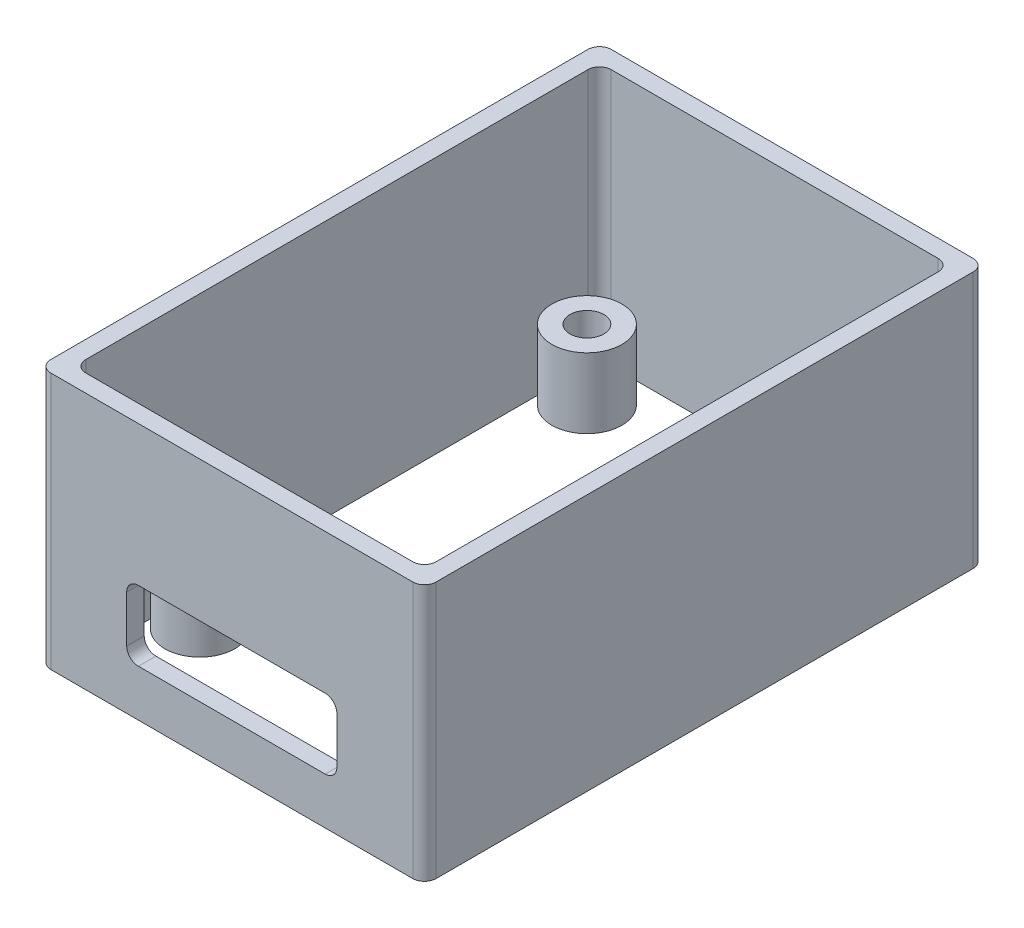
from build123d import *

# Parameters (mm, degrees)
SKETCH1_W                                      = 33
SKETCH1_H                                      = 48
BOSS_EXTRUDE1_DEPTH                            = 22
SKETCH2_W                                      = 30
SKETCH2_H                                      = 45
CUT_EXTRUDE1_DEPTH                             = 25
SKETCH4_R                                      = 3
BOSS_EXTRUDE5_DEPTH                            = 6
BOSS_EXTRUDE5_2_DEPTH                          = 6
BOSS_EXTRUDE5_3_DEPTH                          = 6
BOSS_EXTRUDE5_4_DEPTH                          = 6
SKETCH11_W                                     = 18
SKETCH11_H                                     = 6
CUT_EXTRUDE5_DEPTH                             = 1.5
FILLET5_R                                      = 1
CSK_FOR_M2_5_FLAT_HEAD_MACHINE_SCREW1_AT_COUNT = 2
CSK_FOR_M2_5_FLAT_HEAD_MACHINE_SCREW1_AT_PITCH = 20.32
CSK_FOR_M2_5_FLAT_HEAD_MACHINE_SCREW_2_COUNT   = 2
CSK_FOR_M2_5_FLAT_HEAD_MACHINE_SCREW_2_PITCH   = 38.882192582
CSK_FOR_M2_5_FLAT_HEAD_MACHINE_SCREW_3_COUNT   = 2
CSK_FOR_M2_5_FLAT_HEAD_MACHINE_SCREW_3_PITCH   = 33.15
FILLET6_R                                      = 1


with BuildPart() as part:
    # Sketch1 → Boss-Extrude1 (new body)
    with BuildSketch(Plane(origin=(0, 0, 0), x_dir=(1, 0, 0), z_dir=(0, 1, 0))):
        Rectangle(SKETCH1_W, SKETCH1_H)
    extrude(amount=BOSS_EXTRUDE1_DEPTH)

    # Sketch2 → Cut-Extrude1 (cut)
    with BuildSketch(Plane(origin=(0, 22, 0), x_dir=(1, 0, 0), z_dir=(0, 1, 0))):
        Rectangle(SKETCH2_W, SKETCH2_H)
    extrude(amount=-CUT_EXTRUDE1_DEPTH, mode=Mode.SUBTRACT)

    # Sketch11 → Cut-Extrude5 (cut)
    with BuildSketch(Plane.XY.offset(24)):
        with Locations((0, 7)):
            Rectangle(SKETCH11_W, SKETCH11_H)
    extrude(amount=-CUT_EXTRUDE5_DEPTH, mode=Mode.SUBTRACT)

    # Fillet5
    fillet5_edges = [part.edges().sort_by_distance(p)[0] for p in [
        (15, 11, -22.5),
        (15, 11, 22.5),
        (-15, 11, 22.5),
        (-15, 11, -22.5),
        (-16.5, 11, -24),
        (-16.5, 11, 24),
        (16.5, 11, 24),
        (16.5, 11, -24),
    ]]
    fillet(fillet5_edges, radius=FILLET5_R)

    # Fillet6
    fillet6_edges = [part.edges().sort_by_distance(p)[0] for p in [
        (9, 10, 23.25),
        (9, 4, 23.25),
        (-9, 4, 23.25),
        (-9, 10, 23.25),
    ]]
    fillet(fillet6_edges, radius=FILLET6_R)


with BuildPart() as body_2:
    # Sketch4 → Boss-Extrude5 (new body)
    with BuildSketch(Plane(origin=(0, 2, 0), x_dir=(1, 0, 0), z_dir=(0, 1, 0))):
        with Locations((-10.16, 16.575)):
            Circle(SKETCH4_R)
    extrude(amount=BOSS_EXTRUDE5_DEPTH)


with BuildPart() as body_3:
    # Sketch4 → Boss-Extrude5 2 (new body)
    with BuildSketch(Plane(origin=(0, 2, 0), x_dir=(1, 0, 0), z_dir=(0, 1, 0))):
        with Locations((10.16, -16.575)):
            Circle(SKETCH4_R)
    extrude(amount=BOSS_EXTRUDE5_2_DEPTH)


with BuildPart() as body_4:
    # Sketch4 → Boss-Extrude5 3 (new body)
    with BuildSketch(Plane(origin=(0, 2, 0), x_dir=(1, 0, 0), z_dir=(0, 1, 0))):
        with Locations((10.16, 16.575)):
            Circle(SKETCH4_R)
    extrude(amount=BOSS_EXTRUDE5_3_DEPTH)


with BuildPart() as body_5:
    # Sketch4 → Boss-Extrude5 4 (new body)
    with BuildSketch(Plane(origin=(0, 2, 0), x_dir=(1, 0, 0), z_dir=(0, 1, 0))):
        with Locations((-10.16, -16.575)):
            Circle(SKETCH4_R)
    extrude(amount=BOSS_EXTRUDE5_4_DEPTH)

    # Sketch13 → CSK for M2.5 Flat Head Machine Screw1 (revolve, cut)
    with BuildSketch(Plane(origin=(-10.16, 0, 16.575), x_dir=(0, 0, -1), z_dir=(1, 0, 0))):
        Polygon((0, 0), (0, 22), (1.45, 22), (1.45, 1.3), (2.75, 0), align=None)
    csk_for_m2_5_flat_head_machine_screw1 = revolve(axis=Axis((-10.16, -6.35, 16.575), (0, 1, 0)), mode=Mode.SUBTRACT)


with BuildPart() as body_3_1:
    add(body_3.part)

    # CSK for M2.5 Flat Head Machine Screw1 at: CSK for M2.5 Flat Head Machine Screw1 ×2
    with Locations(*[(i * CSK_FOR_M2_5_FLAT_HEAD_MACHINE_SCREW1_AT_PITCH, 0, 0) for i in range(1, CSK_FOR_M2_5_FLAT_HEAD_MACHINE_SCREW1_AT_COUNT)]):
        add(csk_for_m2_5_flat_head_machine_screw1, mode=Mode.SUBTRACT)


with BuildPart() as body_4_1:
    add(body_4.part)

    # CSK for M2.5 Flat Head Machine Screw 2: CSK for M2.5 Flat Head Machine Screw1 ×2
    with Locations(*[Vector(0.522604273, 0, -0.852575377) * (i * CSK_FOR_M2_5_FLAT_HEAD_MACHINE_SCREW_2_PITCH) for i in range(1, CSK_FOR_M2_5_FLAT_HEAD_MACHINE_SCREW_2_COUNT)]):
        add(csk_for_m2_5_flat_head_machine_screw1, mode=Mode.SUBTRACT)


with BuildPart() as body_2_1:
    add(body_2.part)

    # CSK for M2.5 Flat Head Machine Screw 3: CSK for M2.5 Flat Head Machine Screw1 ×2
    with Locations(*[(0, 0, -i * CSK_FOR_M2_5_FLAT_HEAD_MACHINE_SCREW_3_PITCH) for i in range(1, CSK_FOR_M2_5_FLAT_HEAD_MACHINE_SCREW_3_COUNT)]):
        add(csk_for_m2_5_flat_head_machine_screw1, mode=Mode.SUBTRACT)


solid = Compound([part.part, body_5.part, body_3_1.part, body_4_1.part, body_2_1.part])
